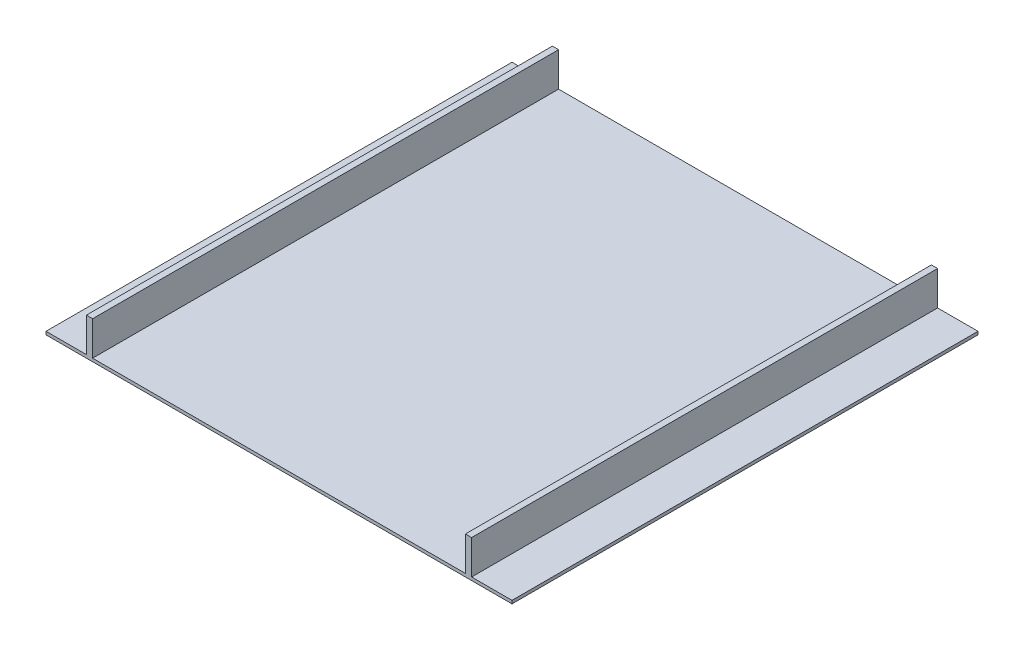
from build123d import *

# Parameters (mm, degrees)
SKETCH2_W           = 1500
SKETCH2_H           = 1500
BOSS_EXTRUDE1_DEPTH = 10
SKETCH3_W           = 20
SKETCH3_H           = 1500
BOSS_EXTRUDE2_DEPTH = 110


with BuildPart() as part:
    # Sketch2 → Boss-Extrude1 (new body)
    with BuildSketch(Plane(origin=(0, 0, 0), x_dir=(1, 0, 0), z_dir=(0, 1, 0))):
        Rectangle(SKETCH2_W, SKETCH2_H)
    extrude(amount=BOSS_EXTRUDE1_DEPTH)

    # Sketch3 → Boss-Extrude2 (add)
    with BuildSketch(Plane(origin=(0, 10, 0), x_dir=(1, 0, 0), z_dir=(0, 1, 0))):
        with Locations((-610, 0)):
            Rectangle(SKETCH3_W, SKETCH3_H)
        with Locations((610, 0)):
            Rectangle(SKETCH3_W, SKETCH3_H)
    extrude(amount=BOSS_EXTRUDE2_DEPTH)


solid = part.part
